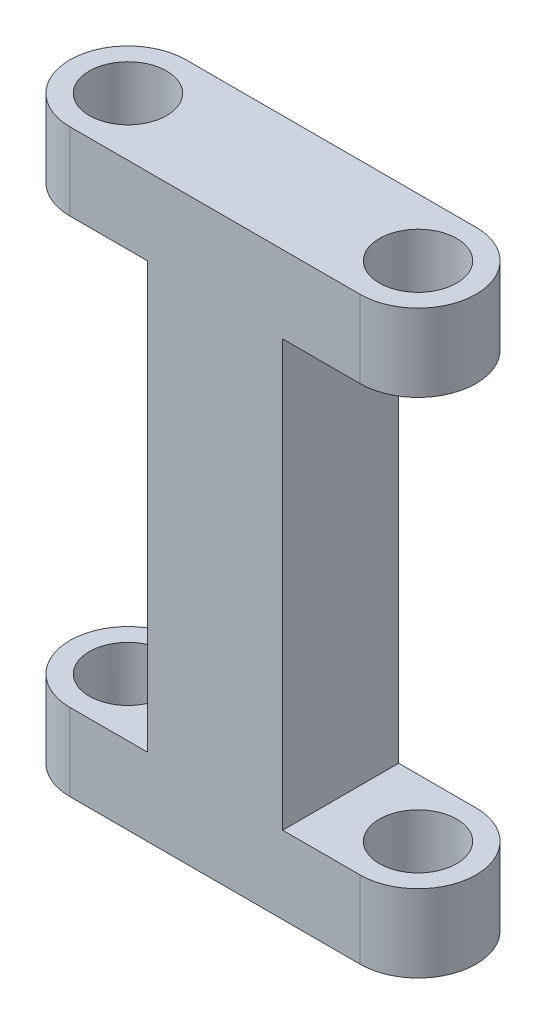
from build123d import *

# Parameters (mm, degrees)
SKETCH1_R           = 2
BOSS_EXTRUDE1_DEPTH = 30
CUT_EXTRUDE1_REACH  = 8
SKETCH3_W           = 7
SKETCH3_H           = 22


with BuildPart() as part:
    # Sketch1 → Boss-Extrude1 (new body)
    with BuildSketch(Plane(origin=(0, 0, 0), x_dir=(1, 0, 0), z_dir=(0, 1, 0))):
        with BuildLine():
            Line((-8.539325843, 3), (6.460674157, 3))
            ThreePointArc((6.460674157, 3), (9.460674157, 0), (6.460674157, -3))
            Line((6.460674157, -3), (-8.539325843, -3))
            ThreePointArc((-8.539325843, -3), (-11.539325843, 0), (-8.539325843, 3))
        make_face()
        with Locations((-8.539325843, 0)):
            Circle(SKETCH1_R, mode=Mode.SUBTRACT)
        with Locations((6.460674157, 0)):
            Circle(SKETCH1_R, mode=Mode.SUBTRACT)
    extrude(amount=BOSS_EXTRUDE1_DEPTH)

    # Sketch3 → Cut-Extrude1 (cut, up to next)
    with BuildSketch(Plane.XY.offset(3), mode=Mode.PRIVATE) as cut_extrude1_sk1:
        with Locations((5.960674157, 15)):
            Rectangle(SKETCH3_W, SKETCH3_H)
    cut_extrude1_tool1 = extrude(cut_extrude1_sk1.sketch, amount=-CUT_EXTRUDE1_REACH, mode=Mode.PRIVATE) & part.part
    add(cut_extrude1_tool1.solids().sort_by_distance((5.960674, 15, 3))[0], mode=Mode.SUBTRACT)
    # Sketch3 → Cut-Extrude1 (cut, up to next)
    with BuildSketch(Plane.XY.offset(3), mode=Mode.PRIVATE) as cut_extrude1_sk2:
        with Locations((-8.039325843, 15)):
            Rectangle(SKETCH3_W, SKETCH3_H)
    cut_extrude1_tool2 = extrude(cut_extrude1_sk2.sketch, amount=-CUT_EXTRUDE1_REACH, mode=Mode.PRIVATE) & part.part
    add(cut_extrude1_tool2.solids().sort_by_distance((-8.039326, 15, 3))[0], mode=Mode.SUBTRACT)


solid = part.part
